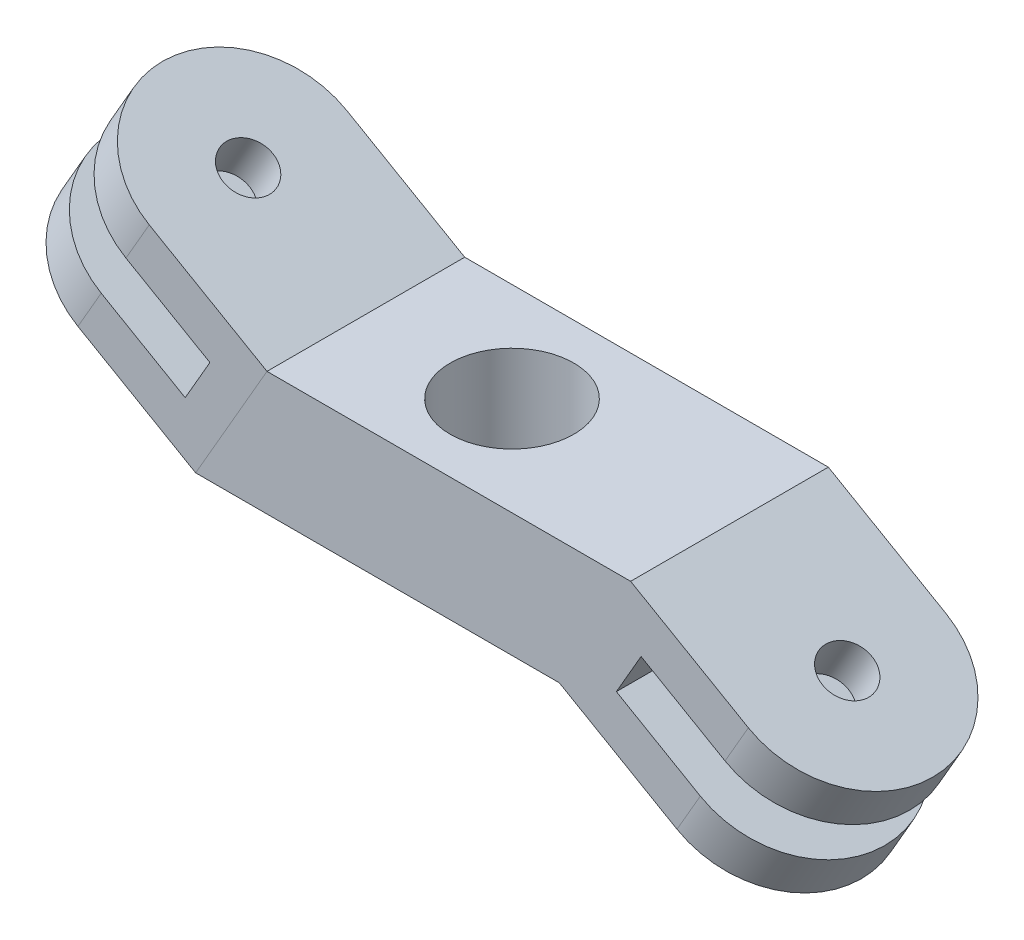
from build123d import *

# Parameters (mm, degrees)
SKETCH_2_R               = 6
EXTRUDE_1_DEPTH          = 5
SKETCH_3_R               = 2.5
CUT_EXTRUDE_1_DEPTH      = 5
SKETCH_4_W               = 5.729511979
SKETCH_4_H               = 5
EXTRUDE_2_DEPTH          = 4
SKETCH_5_W               = 17.690730237
SKETCH_5_H               = 11.693817156
CUT_EXTRUDE_3_DEPTH      = 4.5
EXTRUDE_3_DEPTH          = 5.773503
SKETCH_7_R               = 1
CUT_EXTRUDE_4_DEPTH      = 5.773503
SKETCH_9_W               = 22.757935056
SKETCH_9_H               = 15.650140619
CUT_EXTRUDE_5_DEPTH      = 1
PATTERN_CIRCULAR_3_COUNT = 2
PATTERN_CIRCULAR_4_COUNT = 2
SKETCH_10_W              = 9.588589767
SKETCH_10_H              = 4.25680111
SKETCH_10_W_2            = 8.94427191
SKETCH_10_H_2            = 4.682372666
CUT_EXTRUDE_6_DEPTH      = 10


with BuildPart() as part:
    # Sketch 2 → Extrude 1 (new body)
    with BuildSketch(Plane(origin=(0, 0, 0), x_dir=(1, 0, 0), z_dir=(0, 1, 0))):
        Circle(SKETCH_2_R)
    extrude(amount=EXTRUDE_1_DEPTH)

    # Sketch 3 → Cut-Extrude 1 (cut)
    with BuildSketch(Plane(origin=(0, 5, 0), x_dir=(1, 0, 0), z_dir=(0, 1, 0))):
        Circle(SKETCH_3_R)
    extrude(amount=-CUT_EXTRUDE_1_DEPTH, mode=Mode.SUBTRACT)

    # Sketch 4 → Extrude 2 (add, symmetric)
    with BuildSketch(Plane.XY):
        with Locations((-5.934851886, 2.5)):
            Rectangle(SKETCH_4_W, SKETCH_4_H)
    extrude_2 = extrude(amount=EXTRUDE_2_DEPTH, both=True)

    # Sketch 5 → Cut-Extrude 3 (cut)
    with BuildSketch(Plane(origin=(-6.599705906, 3.810341982, 0), x_dir=(0, 0, 1), z_dir=(0.866025404, -0.5, 0))):
        with Locations((1.152187915, 2.412038691)):
            Rectangle(SKETCH_5_W, SKETCH_5_H)
    cut_extrude_3 = extrude(amount=-CUT_EXTRUDE_3_DEPTH, mode=Mode.SUBTRACT)

    # Mirror 1: Extrude 2 across plane
    add(extrude_2.mirror(Plane(origin=(0, 0, 0), x_dir=(0, 0, 1), z_dir=(1, 0, 0))))

    # Pattern Circular 3: Cut-Extrude 3 ×2 about axis
    pattern_circular_3_axis = Axis((0, 2.5, -6.6), (0, 0, 1))
    for i in range(1, PATTERN_CIRCULAR_3_COUNT):
        add(cut_extrude_3.rotate(pattern_circular_3_axis, i * 360 / PATTERN_CIRCULAR_3_COUNT), mode=Mode.SUBTRACT)


with BuildPart() as body_2:
    # Sketch 6 → Extrude 3 (new body)
    with BuildSketch(Plane(origin=(0.686849377, 1.189658018, 0), x_dir=(0, 0, 1), z_dir=(0.5, 0.866025404, 0))):
        with BuildLine():
            Line((-4, -13.121503046), (-4, -7.620683963))
            Line((-4, -7.620683963), (4, -7.620683963))
            Line((4, -7.620683963), (4, -13.121503046))
            ThreePointArc((4, -13.121503046), (0, -17.121503046), (-4, -13.121503046))
        make_face()
    extrude_3 = extrude(amount=-EXTRUDE_3_DEPTH)

    # Sketch 7 → Cut-Extrude 4 (cut)
    with BuildSketch(Plane(origin=(0.686849377, 1.189658018, 0), x_dir=(0.866025404, -0.5, 0), z_dir=(0.5, 0.866025404, 0))):
        with Locations((-13.121503046, 0)):
            Circle(SKETCH_7_R)
    cut_extrude_4 = extrude(amount=-CUT_EXTRUDE_4_DEPTH, mode=Mode.SUBTRACT)

    # Sketch 9 → Cut-Extrude 5 (cut, symmetric)
    with BuildSketch(Plane(origin=(-0.756526296, -1.310341982, 0), x_dir=(0.866025404, -0.5, 0), z_dir=(0.5, 0.866025404, 0))):
        with Locations((-20.577581029, 0.471972115)):
            Rectangle(SKETCH_9_W, SKETCH_9_H)
    cut_extrude_5 = extrude(amount=CUT_EXTRUDE_5_DEPTH, both=True, mode=Mode.SUBTRACT)


with BuildPart() as part_1:
    add(part.part)

    # Pattern Circular 4: Extrude 3, Cut-Extrude 4, Cut-Extrude 5 ×2 about axis
    pattern_circular_4_axis = Axis((0, 2.5, 0), (0, 0, 1))
    for i in range(1, PATTERN_CIRCULAR_4_COUNT):
        add(extrude_3.rotate(pattern_circular_4_axis, i * 360 / PATTERN_CIRCULAR_4_COUNT))
        add(cut_extrude_4.rotate(pattern_circular_4_axis, i * 360 / PATTERN_CIRCULAR_4_COUNT), mode=Mode.SUBTRACT)
        add(cut_extrude_5.rotate(pattern_circular_4_axis, i * 360 / PATTERN_CIRCULAR_4_COUNT), mode=Mode.SUBTRACT)

    # Sketch 10 → Cut-Extrude 6 (cut)
    with BuildSketch(Plane(origin=(0, 5, 0), x_dir=(1, 0, 0), z_dir=(0, 1, 0))):
        with Locations((-0.322158928, -6.128400555)):
            Rectangle(SKETCH_10_W, SKETCH_10_H)
        with Locations((0, 6.341186333)):
            Rectangle(SKETCH_10_W_2, SKETCH_10_H_2)
    extrude(amount=-CUT_EXTRUDE_6_DEPTH, mode=Mode.SUBTRACT)


solid = Compound([body_2.part, part_1.part])
